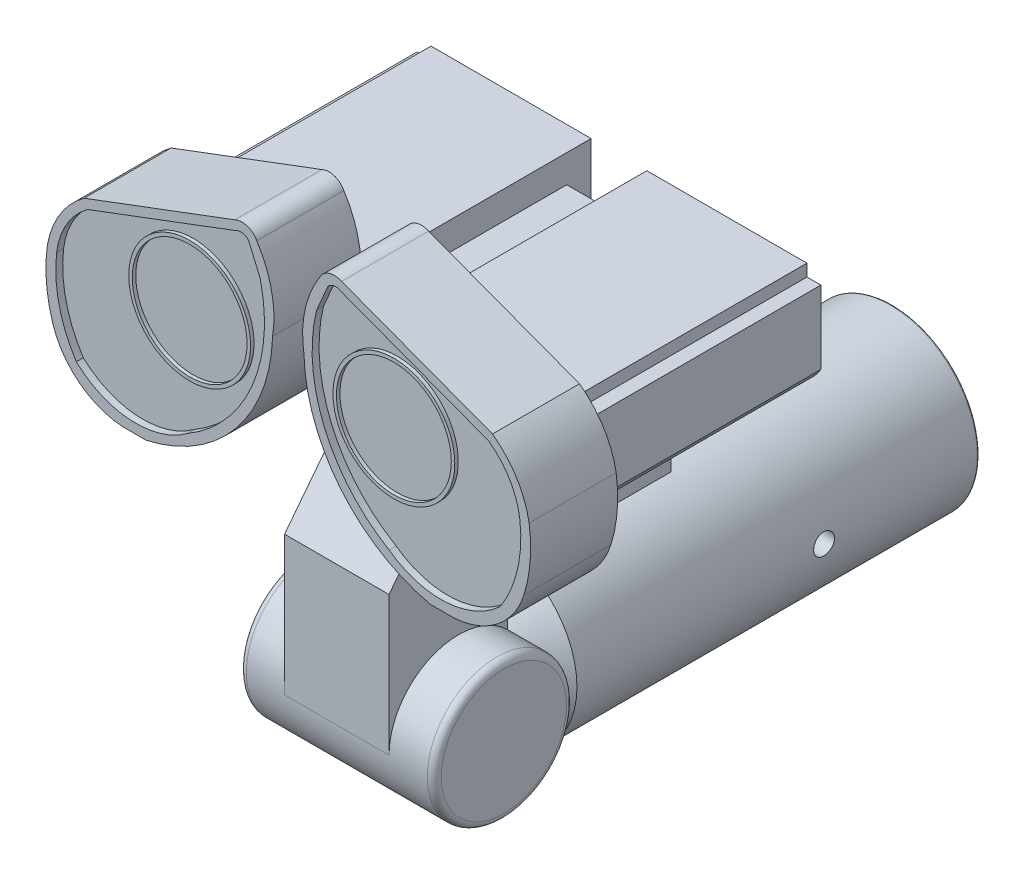
from build123d import *

# Parameters (mm, degrees)
HINGE_CONNECTED_TO_BOTTOM_TUBE_DEPTH      = 1.4
HINGE_CONNECTED_TO_BOTTOM_TUBE_DEPTH_BACK = 1.4
SKETCH3_R                                 = 1
FILLET_ON_HINGE_R                         = 0.1
BASE_CONNECTED_TO_EYES_DEPTH              = 0.75
BASE_CONNECTED_TO_EYES_DEPTH_BACK         = 0.75
EYE_BACKING_DEPTH                         = 3.5
SKETCH7_W                                 = 0.8
SKETCH7_H                                 = 3.5
EYE_BACKING_DETAILS_DEPTH                 = 1.07
SKETCH8_W                                 = 0.8
SKETCH8_H                                 = 1.9
MIDDLE_OF_EYE_BACKING_DEPTH               = 0.67
SKETCH12_R                                = 0.875
OUTER_EYE_DEPTH                           = 1.25
INNER_EYE_CUT_DEPTH                       = 0.1
SKETCH12_5_R                              = 0.875
SKETCH12_5_R_2                            = 0.825
OUTER_LENS_DEPTH                          = 1.2
SKETCH12_7_R                              = 0.825
INNER_LENS_CUT_DEPTH                      = 1.15
CUT_EXTRUDE3_REACH                        = 13.236
SKETCH15_R                                = 0.15
CUT_EXTRUDE3_DIRECTION_2_REACH            = 13.236
SKETCH12_6_R                              = 0.825
BOSS_EXTRUDE16_DEPTH                      = 1.15
SCALE1_SCALE                              = 1.75


with BuildPart() as part:
    # Sketch2 → Bottom tube (revolve)
    with BuildSketch(Plane(origin=(0, 0, 0), x_dir=(0, 0, -1), z_dir=(1, 0, 0))):
        with BuildLine():
            Line((-6.25, 0), (0.163609492, 0))
            add(Edge.make_bspline(
                [(0.163609492, 0), (0.163609492, 1.25), (0, 1.25)],
                knots=[4.71238898, 4.71238898, 4.71238898, 6.283185307, 6.283185307, 6.283185307], degree=2, weights=[1, 0.707106781, 1]))
            Line((0, 1.25), (-5.75, 1.25))
            Line((-5.75, 1.25), (-6.25, 0.75))
            Line((-6.25, 0.75), (-6.25, 0))
        make_face()
    revolve(axis=Axis((0, 0, 6.25), (0, 0, -1)))

    # Sketch3 → Hinge connected to bottom tube (add, two sides: drawn at the far end of the back side and taken through both)
    with BuildSketch(Plane(origin=(0, 0, 0), x_dir=(0, 0, -1), z_dir=(1, 0, 0)).offset(-HINGE_CONNECTED_TO_BOTTOM_TUBE_DEPTH_BACK)):
        with Locations((-6.95, 0)):
            Circle(SKETCH3_R)
    extrude(amount=HINGE_CONNECTED_TO_BOTTOM_TUBE_DEPTH + HINGE_CONNECTED_TO_BOTTOM_TUBE_DEPTH_BACK)

    # fillet on hinge
    fillet_on_hinge_edges = [part.edges().sort_by_distance(p)[0] for p in [
        (1.4, 0, 7.95),
        (-1.4, 0, 7.95),
    ]]
    fillet(fillet_on_hinge_edges, radius=FILLET_ON_HINGE_R)

    # Sketch4 → base connected to eyes (add, two sides: drawn at the far end of the back side and taken through both)
    with BuildSketch(Plane(origin=(0, 0, 0), x_dir=(0, 0, -1), z_dir=(1, 0, 0)).offset(-BASE_CONNECTED_TO_EYES_DEPTH_BACK)):
        with BuildLine():
            Line((-7.95, 0), (-7.95, 2))
            Line((-7.95, 2), (-6.39677242, 4))
            Line((-6.39677242, 4), (-3.89677242, 4))
            Line((-3.89677242, 4), (-3.89677242, 1.5))
            Line((-3.89677242, 1.5), (-6.25, 1.5))
            Line((-6.25, 1.5), (-6.25, 0.714142843))
            ThreePointArc((-6.25, 0.714142843), (-7.337298335, 0.921954446), (-7.95, 0))
        make_face()
    extrude(amount=BASE_CONNECTED_TO_EYES_DEPTH + BASE_CONNECTED_TO_EYES_DEPTH_BACK)

    # Sketch5 → Eye backing (add)
    with BuildSketch(Plane(origin=(0, 0, 3.89677242), x_dir=(-1, 0, 0), z_dir=(0, 0, -1))):
        with BuildLine():
            Line((0.75, 3.5), (2.25, 3.5))
            ThreePointArc((2.25, 3.5), (2.62408667, 3.581702047), (2.9, 3.847197614))
            Line((2.9, 3.847197614), (2.9, 4.897197614))
            Line((2.9, 4.897197614), (2.7, 4.897197614))
            Line((2.7, 4.897197614), (2.7, 5.07))
            Line((2.7, 5.07), (-2.7, 5.07))
            Line((-2.7, 5.07), (-2.7, 4.897197614))
            Line((-2.7, 4.897197614), (-2.9, 4.897197614))
            Line((-2.9, 4.897197614), (-2.9, 3.847197614))
            ThreePointArc((-2.9, 3.847197614), (-2.62408667, 3.581702047), (-2.25, 3.5))
            Line((-2.25, 3.5), (-0.75, 3.5))
            Line((-0.75, 3.5), (-0.75, 4))
            Line((-0.75, 4), (0.75, 4))
            Line((0.75, 4), (0.75, 3.5))
        make_face()
    extrude(amount=-EYE_BACKING_DEPTH)

    # Sketch7 → Eye backing details (cut)
    with BuildSketch(Plane(origin=(0, 5.07, 0), x_dir=(1, 0, 0), z_dir=(0, 1, 0))):
        with Locations((0, -5.64677242)):
            Rectangle(SKETCH7_W, SKETCH7_H)
    extrude(amount=-EYE_BACKING_DETAILS_DEPTH, mode=Mode.SUBTRACT)

    # Sketch8 → Middle of eye backing (add)
    with BuildSketch(Plane(origin=(0, 4, 0), x_dir=(1, 0, 0), z_dir=(0, 1, 0))):
        with Locations((0, -5.19677242)):
            Rectangle(SKETCH8_W, SKETCH8_H)
    extrude(amount=MIDDLE_OF_EYE_BACKING_DEPTH)

    # Sketch12 → Outer eye (add)
    # profile 1 of 2: a face of its own
    with BuildSketch(Plane.XY.offset(7.39677242)):
        with BuildLine():
            ThreePointArc((-0.450961505, 6.145644801), (-0.587867618, 6.261837628), (-0.767083386, 6.250623109))
            Line((-0.767083386, 6.250623109), (-2.933329516, 5.436310045))
            ThreePointArc((-2.933329516, 5.436310045), (-3.278345677, 5.065387345), (-3.459739663, 4.592401064))
            ThreePointArc((-3.459739663, 4.592401064), (-3.474536987, 4.120986543), (-3.384350783, 3.658042637))
            ThreePointArc((-3.384350783, 3.658042637), (-3.001009551, 3.106292928), (-2.371698574, 2.871035758))
            Line((-2.371698574, 2.871035758), (-2.041485898, 2.871035758))
            ThreePointArc((-2.041485898, 2.871035758), (-0.756304939, 3.659066468), (-0.225316176, 5.07))
            ThreePointArc((-0.225316176, 5.07), (-0.238383659, 5.628748724), (-0.450961505, 6.145644801))
        make_face()
        with Locations((-1.466642551, 4.746410471)):
            Circle(SKETCH12_R, mode=Mode.SUBTRACT)
    # profile 2 of 2: a face of its own
    with BuildSketch(Plane.XY.offset(7.39677242)):
        with BuildLine():
            Line((2.041485898, 2.871035758), (2.371698574, 2.871035758))
            ThreePointArc((2.371698574, 2.871035758), (3.001009551, 3.106292928), (3.384350783, 3.658042637))
            ThreePointArc((3.384350783, 3.658042637), (3.474536987, 4.120986543), (3.459739663, 4.592401064))
            ThreePointArc((3.459739663, 4.592401064), (3.278345677, 5.065387345), (2.933329516, 5.436310045))
            Line((2.933329516, 5.436310045), (0.767083386, 6.250623109))
            ThreePointArc((0.767083386, 6.250623109), (0.587867618, 6.261837628), (0.450961505, 6.145644801))
            ThreePointArc((0.450961505, 6.145644801), (0.238383659, 5.628748724), (0.225316176, 5.07))
            ThreePointArc((0.225316176, 5.07), (0.756304939, 3.659066468), (2.041485898, 2.871035758))
        make_face()
        with Locations((1.466642551, 4.746410471)):
            Circle(SKETCH12_R, mode=Mode.SUBTRACT)
    extrude(amount=OUTER_EYE_DEPTH)

    # Sketch13 → Inner eye cut (cut)
    with BuildSketch(Plane.XY.offset(8.64677242)):
        with BuildLine():
            Line((-0.757964351, 6.121312443), (-2.880162803, 5.322245904))
            ThreePointArc((-2.880162803, 5.322245904), (-3.184019481, 4.988025414), (-3.327634423, 4.55976502))
            ThreePointArc((-3.327634423, 4.55976502), (-3.29208127, 3.928007422), (-3.044809473, 3.345565711))
            ThreePointArc((-3.044809473, 3.345565711), (-2.263619647, 3.009419304), (-1.448470515, 3.251873102))
            ThreePointArc((-1.448470515, 3.251873102), (-0.52016025, 4.307569927), (-0.404930121, 5.708633007))
            Line((-0.404930121, 5.708633007), (-0.570058708, 6.091643131))
            ThreePointArc((-0.570058708, 6.091643131), (-0.658423401, 6.141869268), (-0.757964351, 6.121312443))
        make_face()
        with BuildLine():
            Line((0.570058708, 6.091643131), (0.404930121, 5.708633007))
            ThreePointArc((0.404930121, 5.708633007), (0.52016025, 4.307569927), (1.448470515, 3.251873102))
            ThreePointArc((1.448470515, 3.251873102), (2.263619647, 3.009419304), (3.044809473, 3.345565711))
            ThreePointArc((3.044809473, 3.345565711), (3.29208127, 3.928007422), (3.327634423, 4.55976502))
            ThreePointArc((3.327634423, 4.55976502), (3.184019481, 4.988025414), (2.880162803, 5.322245904))
            Line((2.880162803, 5.322245904), (0.757964351, 6.121312443))
            ThreePointArc((0.757964351, 6.121312443), (0.658423401, 6.141869268), (0.570058708, 6.091643131))
        make_face()
    extrude(amount=-INNER_EYE_CUT_DEPTH, mode=Mode.SUBTRACT)

    # Sketch12_5 → Outer lens (add)
    # profile 1 of 2: a face of its own
    with BuildSketch(Plane.XY.offset(7.39677242)):
        with Locations((-1.466642551, 4.746410471)):
            Circle(SKETCH12_5_R)
        with Locations((-1.466642551, 4.746410471)):
            Circle(SKETCH12_5_R_2, mode=Mode.SUBTRACT)
    # profile 2 of 2: a face of its own
    with BuildSketch(Plane.XY.offset(7.39677242)):
        with Locations((1.466642551, 4.746410471)):
            Circle(SKETCH12_5_R)
        with Locations((1.466642551, 4.746410471)):
            Circle(SKETCH12_5_R_2, mode=Mode.SUBTRACT)
    extrude(amount=OUTER_LENS_DEPTH)

    # Sketch12_7 → Inner lens cut (add)
    with BuildSketch(Plane.XY.offset(7.39677242)):
        with Locations((-1.466642551, 4.746410471)):
            Circle(SKETCH12_7_R)
        with Locations((1.466642551, 4.746410471)):
            Circle(SKETCH12_7_R)
    extrude(amount=INNER_LENS_CUT_DEPTH)

    # Sketch15 → Cut-Extrude3 (cut, up to next)
    with BuildSketch(Plane(origin=(0, 0, 0), x_dir=(0, 0, -1), z_dir=(1, 0, 0)), mode=Mode.PRIVATE) as cut_extrude3_sk1:
        with Locations((-2.2, 0)):
            Circle(SKETCH15_R)
    cut_extrude3_tool1 = extrude(cut_extrude3_sk1.sketch, amount=-CUT_EXTRUDE3_REACH, mode=Mode.PRIVATE) & part.part
    add(cut_extrude3_tool1.solids().sort_by_distance((0, 0, 2.2))[0], mode=Mode.SUBTRACT)

    # Sketch15 → Cut-Extrude3 direction 2 (cut, up to next)
    with BuildSketch(Plane(origin=(0, 0, 0), x_dir=(0, 0, -1), z_dir=(1, 0, 0)), mode=Mode.PRIVATE) as cut_extrude3_direction_2_sk1:
        with Locations((-2.2, 0)):
            Circle(SKETCH15_R)
    cut_extrude3_direction_2_tool1 = extrude(cut_extrude3_direction_2_sk1.sketch, amount=CUT_EXTRUDE3_DIRECTION_2_REACH, mode=Mode.PRIVATE) & part.part
    add(cut_extrude3_direction_2_tool1.solids().sort_by_distance((0, 0, 2.2))[0], mode=Mode.SUBTRACT)

    # Sketch12_6 → Boss-Extrude16 (add)
    with BuildSketch(Plane.XY.offset(7.39677242)):
        with Locations((-1.466642551, 4.746410471)):
            Circle(SKETCH12_6_R)
        with Locations((1.466642551, 4.746410471)):
            Circle(SKETCH12_6_R)
    extrude(amount=BOSS_EXTRUDE16_DEPTH)


with BuildPart() as part_1:
    # Scale1: scaled about (0, 0, 0)
    add(part.part.scale(SCALE1_SCALE))


solid = part_1.part
